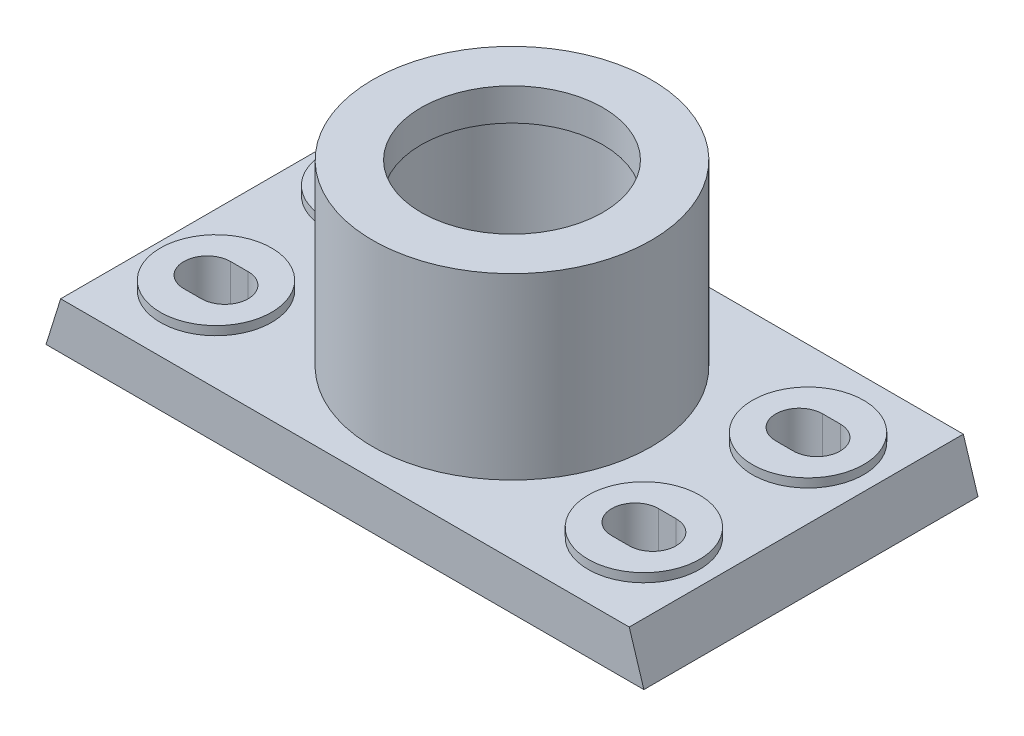
from build123d import *

# Parameters (mm, degrees)
BOSS_EXTRUDE1_DEPTH = 114
SKETCH3_W           = 82.5
SKETCH3_H           = 94
CUT_EXTRUDE1_DEPTH  = 3
CUT_EXTRUDE2_DEPTH  = 17
SKETCH5_R           = 19
BOSS_EXTRUDE2_DEPTH = 3
SKETCH6_R           = 47.5
SKETCH6_R_2         = 31
BOSS_EXTRUDE4_DEPTH = 61
SKETCH8_W           = 3
SKETCH8_H           = 35.544994967
SKETCH9_R           = 1.5
CUT_EXTRUDE3_DEPTH  = 5


with BuildPart() as part:
    # Sketch2 → Boss-Extrude1 (new body)
    with BuildSketch(Plane.XY):
        Polygon((-102, 0), (-97, 16), (97, 16), (102, 0), align=None)
    extrude(amount=-BOSS_EXTRUDE1_DEPTH)

    # Sketch3 → Cut-Extrude1 (cut)
    with BuildSketch(Plane.XZ):
        with Locations((-50.75, -57)):
            Rectangle(SKETCH3_W, SKETCH3_H)
        with Locations((50.75, -57)):
            Rectangle(SKETCH3_W, SKETCH3_H)
    extrude(amount=-CUT_EXTRUDE1_DEPTH, mode=Mode.SUBTRACT)

    # Sketch4 → Cut-Extrude2 (cut, through all)
    with BuildSketch(Plane(origin=(0, 16, 0), x_dir=(1, 0, 0), z_dir=(0, 1, 0))):
        with BuildLine():
            Line((-76, 77), (-70, 77))
            ThreePointArc((-70, 77), (-62, 85), (-70, 93))
            Line((-70, 93), (-76, 93))
            ThreePointArc((-76, 93), (-84, 85), (-76, 77))
        make_face()
        with BuildLine():
            ThreePointArc((70, 77), (62, 85), (70, 93))
            Line((70, 93), (76, 93))
            ThreePointArc((76, 93), (84, 85), (76, 77))
            Line((76, 77), (70, 77))
        make_face()
        with BuildLine():
            ThreePointArc((-70, 37), (-62, 29), (-70, 21))
            Line((-70, 21), (-76, 21))
            ThreePointArc((-76, 21), (-84, 29), (-76, 37))
            Line((-76, 37), (-70, 37))
        make_face()
        with BuildLine():
            Line((76, 37), (70, 37))
            ThreePointArc((70, 37), (62, 29), (70, 21))
            Line((70, 21), (76, 21))
            ThreePointArc((76, 21), (84, 29), (76, 37))
        make_face()
    extrude(amount=-CUT_EXTRUDE2_DEPTH, mode=Mode.SUBTRACT)

    # Sketch5 → Boss-Extrude2 (add)
    with BuildSketch(Plane(origin=(0, 16, 0), x_dir=(1, 0, 0), z_dir=(0, 1, 0))):
        with Locations(Location((-73, 85, 0), (0, 0, 180))):  # turned: the seam where the file's is
            Circle(SKETCH5_R)
        with BuildLine():
            ThreePointArc((-70, 93), (-62, 85), (-70, 77))
            Line((-70, 77), (-76, 77))
            ThreePointArc((-76, 77), (-84, 85), (-76, 93))
            Line((-76, 93), (-70, 93))
        make_face(mode=Mode.SUBTRACT)
        with Locations(Location((73, 85, 0), (0, 0, 180))):  # turned: the seam where the file's is
            Circle(SKETCH5_R)
        with BuildLine():
            ThreePointArc((76, 93), (84, 85), (76, 77))
            Line((76, 77), (70, 77))
            ThreePointArc((70, 77), (62, 85), (70, 93))
            Line((70, 93), (76, 93))
        make_face(mode=Mode.SUBTRACT)
        with Locations(Location((73, 29, 0), (0, 0, 180))):  # turned: the seam where the file's is
            Circle(SKETCH5_R)
        with BuildLine():
            ThreePointArc((70, 21), (62, 29), (70, 37))
            Line((70, 37), (76, 37))
            ThreePointArc((76, 37), (84, 29), (76, 21))
            Line((76, 21), (70, 21))
        make_face(mode=Mode.SUBTRACT)
        with Locations(Location((-73, 29, 0), (0, 0, 180))):  # turned: the seam where the file's is
            Circle(SKETCH5_R)
        with BuildLine():
            ThreePointArc((-76, 21), (-84, 29), (-76, 37))
            Line((-76, 37), (-70, 37))
            ThreePointArc((-70, 37), (-62, 29), (-70, 21))
            Line((-70, 21), (-76, 21))
        make_face(mode=Mode.SUBTRACT)
    extrude(amount=BOSS_EXTRUDE2_DEPTH)

    # Sketch6 → Boss-Extrude4 (add)
    with BuildSketch(Plane(origin=(0, 16, 0), x_dir=(1, 0, 0), z_dir=(0, 1, 0))):
        with Locations(Location((0, 57, 0), (0, 0, 180))):  # turned: the seam where the file's is
            Circle(SKETCH6_R)
        with Locations(Location((0, 57, 0), (0, 0, 180))):  # turned: the seam where the file's is
            Circle(SKETCH6_R_2, mode=Mode.SUBTRACT)
    extrude(amount=BOSS_EXTRUDE4_DEPTH)

    # Sketch8 → Cut-Revolve1 (revolve, cut)
    with BuildSketch(Plane.XY.offset(-57)):
        with Locations((-31, 48.227502517)):
            Rectangle(SKETCH8_W, SKETCH8_H)
    revolve(axis=Axis((0, 107.106199385, -57), (0, -1, 0)), mode=Mode.SUBTRACT)

    # Sketch9 → Cut-Extrude3 (cut)
    with BuildSketch(Plane(origin=(0, 16, 0), x_dir=(1, 0, 0), z_dir=(0, 1, 0))):
        with Locations(Location((-22, 57, 0), (0, 0, 180))):  # turned: the seam where the file's is
            Circle(SKETCH9_R)
    extrude(amount=-CUT_EXTRUDE3_DEPTH, mode=Mode.SUBTRACT)


solid = part.part
